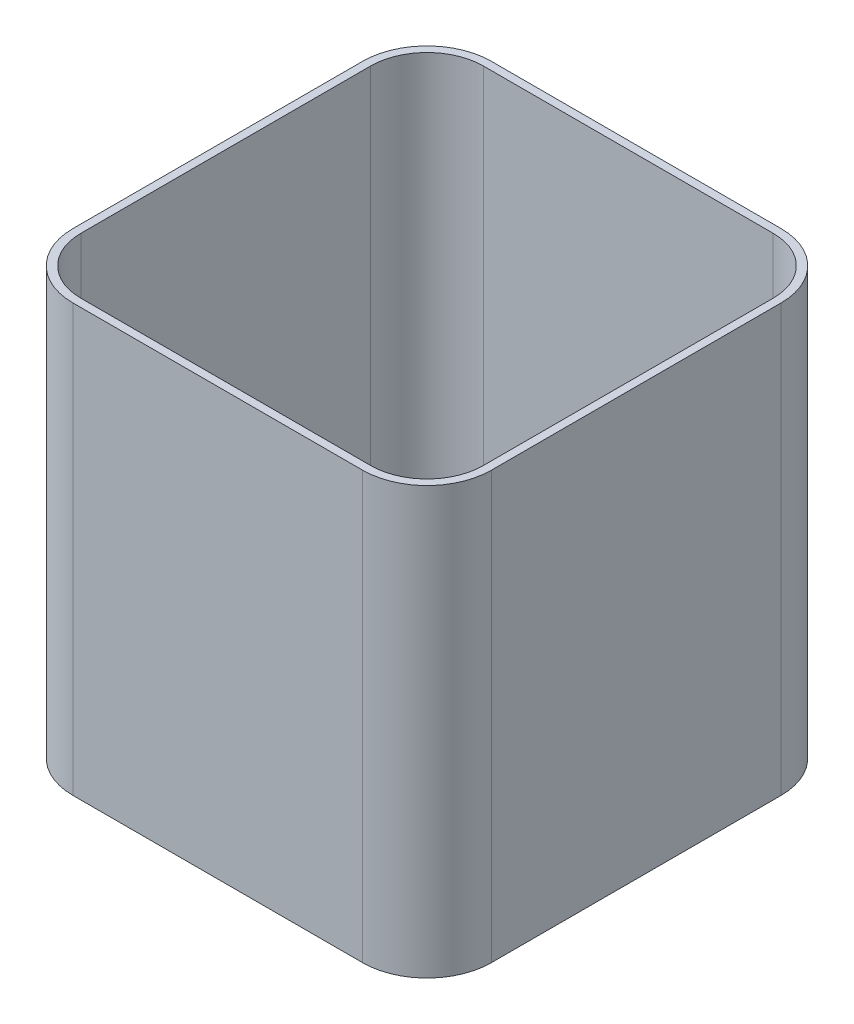
from build123d import *

# Parameters (mm, degrees)
BOSS_EXTRUDE1_DEPTH = 336.55


with BuildPart() as part:
    # Sketch1 → Boss-Extrude1 (new body)
    with BuildSketch(Plane(origin=(0, 0, 0), x_dir=(1, 0, 0), z_dir=(0, 1, 0))):
        with BuildLine():
            Line((-114.3, -165.1), (114.3, -165.1))
            ThreePointArc((114.3, -165.1), (150.221024484, -150.221024484), (165.1, -114.3))
            Line((165.1, -114.3), (165.1, 114.3))
            ThreePointArc((165.1, 114.3), (150.221024484, 150.221024484), (114.3, 165.1))
            Line((114.3, 165.1), (-114.3, 165.1))
            ThreePointArc((-114.3, 165.1), (-150.221024484, 150.221024484), (-165.1, 114.3))
            Line((-165.1, 114.3), (-165.1, -114.3))
            ThreePointArc((-165.1, -114.3), (-150.221024484, -150.221024484), (-114.3, -165.1))
        make_face()
        with BuildLine():
            Line((-114.3, 158.75), (114.3, 158.75))
            ThreePointArc((114.3, 158.75), (145.730896424, 145.730896424), (158.75, 114.3))
            Line((158.75, 114.3), (158.75, -114.3))
            ThreePointArc((158.75, -114.3), (145.730896424, -145.730896424), (114.3, -158.75))
            Line((114.3, -158.75), (-114.3, -158.75))
            ThreePointArc((-114.3, -158.75), (-145.730896424, -145.730896424), (-158.75, -114.3))
            Line((-158.75, -114.3), (-158.75, 114.3))
            ThreePointArc((-158.75, 114.3), (-145.730896424, 145.730896424), (-114.3, 158.75))
        make_face(mode=Mode.SUBTRACT)
    extrude(amount=BOSS_EXTRUDE1_DEPTH)


solid = part.part
